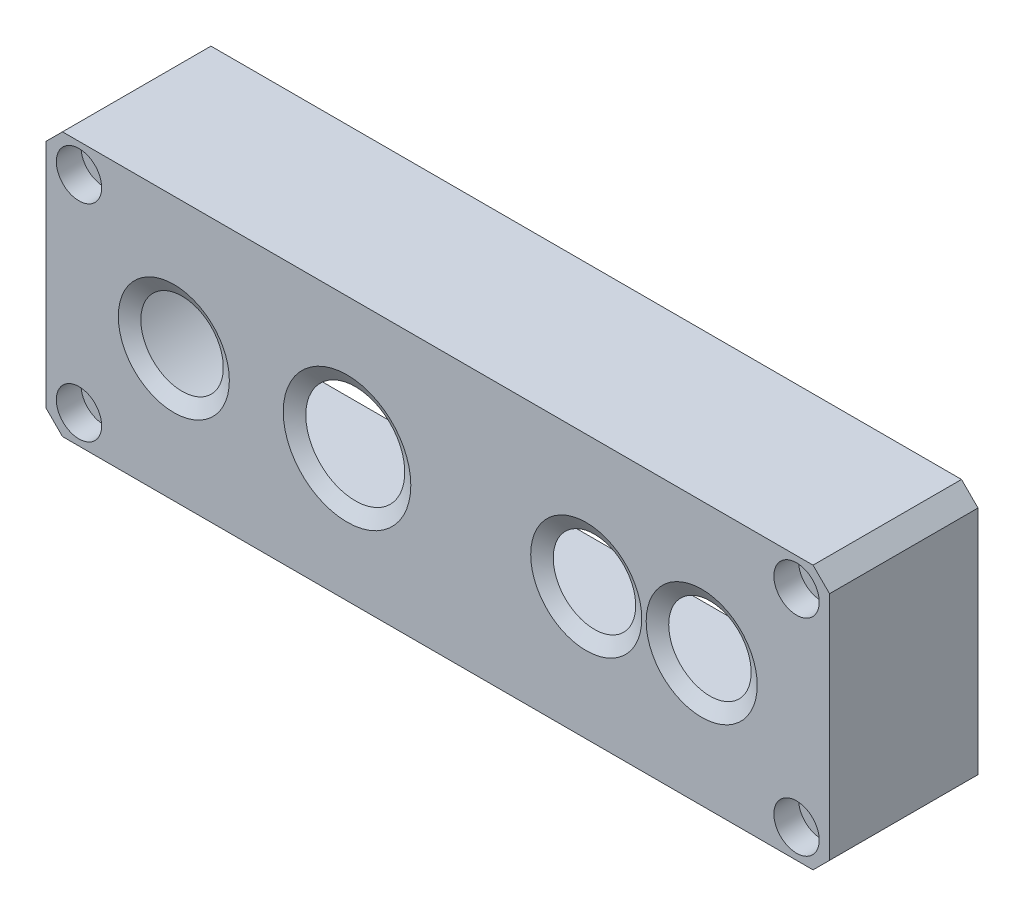
from build123d import *

# Parameters (mm, degrees)
EXTRUDE_1_DEPTH     = 17
SKETCH_2_R          = 6
SKETCH_2_R_2        = 5
EXTRUDE_2_DEPTH     = 1
SKETCH_3_R          = 5
SKETCH_3_R_2        = 6
CUT_EXTRUDE_1_DEPTH = 11
CUT_EXTRUDE_1_TAPER = -60
EXTRUDE_5_DEPTH     = 17
SKETCH_9_R          = 1.3
CUT_EXTRUDE_6_DEPTH = 19.0000001
SKETCH_10_R         = 2.75
CUT_EXTRUDE_7_DEPTH = 3


with BuildPart() as part:
    # 草图1 → 凸台-拉伸1 (new body)
    with BuildSketch(Plane.XY):
        Polygon((-229.462722424, 108.123928313), (-138.462722424, 108.123928313), (-136.462722424, 106.123928313), (-136.462722424, 78.123928313), (-138.462722424, 76.123928313), (-229.462722424, 76.123928313), (-231.462722424, 78.123928313), (-231.462722424, 106.123928313), align=None)
        Polygon((-228.6342953, 106.123928313), (-139.291149549, 106.123928313), (-138.462722424, 105.295501188), (-138.462722424, 78.952355437), (-139.291149549, 78.123928313), (-228.6342953, 78.123928313), (-229.462722424, 78.952355437), (-229.462722424, 105.295501188), align=None, mode=Mode.SUBTRACT)
    extrude(amount=-EXTRUDE_1_DEPTH)

    # 草图2 → 凸台-拉伸2 (add)
    with BuildSketch(Plane.XY):
        Polygon((-136.462722424, 106.123928313), (-138.462722424, 108.123928313), (-229.462722424, 108.123928313), (-231.462722424, 106.123928313), (-231.462722424, 78.123928313), (-229.462722424, 76.123928313), (-138.462722424, 76.123928313), (-136.462722424, 78.123928313), align=None)
        with Locations((-194.962722424, 92.123928313)):
            Circle(SKETCH_2_R, mode=Mode.SUBTRACT)
        with Locations((-165.962722424, 92.123928313)):
            Circle(SKETCH_2_R_2, mode=Mode.SUBTRACT)
        with Locations((-215.962722424, 92.123928313)):
            Circle(SKETCH_2_R_2, mode=Mode.SUBTRACT)
        with Locations((-151.962722424, 92.123928313)):
            Circle(SKETCH_2_R_2, mode=Mode.SUBTRACT)
    extrude(amount=EXTRUDE_2_DEPTH)

    # 草图3 → 切除-拉伸1 (cut)
    with BuildSketch(Plane(origin=(0, 0, 0), x_dir=(-1, 0, 0), z_dir=(0, 0, -1))):
        with Locations((151.962722424, 92.123928313)):
            Circle(SKETCH_3_R)
        with Locations((215.962722424, 92.123928313)):
            Circle(SKETCH_3_R)
        with Locations((194.962722424, 92.123928313)):
            Circle(SKETCH_3_R_2)
        with Locations((165.962722424, 92.123928313)):
            Circle(SKETCH_3_R)
    extrude(amount=-CUT_EXTRUDE_1_DEPTH, taper=CUT_EXTRUDE_1_TAPER, mode=Mode.SUBTRACT)

    # 草图8 → 凸台-拉伸5 (add)
    with BuildSketch(Plane(origin=(0, 0, 0), x_dir=(-1, 0, 0), z_dir=(0, 0, -1))):
        with BuildLine():
            ThreePointArc((229.462722424, 92.123928313), (225.801557189, 83.285093548), (216.962722424, 79.623928313))
            Line((216.962722424, 79.623928313), (150.962722424, 79.623928313))
            ThreePointArc((150.962722424, 79.623928313), (142.123887659, 83.285093548), (138.462722424, 92.123928313))
            Line((138.462722424, 92.123928313), (138.462722424, 78.952355437))
            Line((138.462722424, 78.952355437), (139.291149549, 78.123928313))
            Line((139.291149549, 78.123928313), (228.6342953, 78.123928313))
            Line((228.6342953, 78.123928313), (229.462722424, 78.952355437))
            Line((229.462722424, 78.952355437), (229.462722424, 92.123928313))
        make_face()
        with BuildLine():
            ThreePointArc((216.962722424, 104.623928313), (225.801557189, 100.962763077), (229.462722424, 92.123928313))
            Line((229.462722424, 92.123928313), (229.462722424, 105.295501188))
            Line((229.462722424, 105.295501188), (228.6342953, 106.123928313))
            Line((228.6342953, 106.123928313), (139.291149549, 106.123928313))
            Line((139.291149549, 106.123928313), (138.462722424, 105.295501188))
            Line((138.462722424, 105.295501188), (138.462722424, 92.123928313))
            ThreePointArc((138.462722424, 92.123928313), (142.123887659, 100.962763077), (150.962722424, 104.623928313))
            Line((150.962722424, 104.623928313), (216.962722424, 104.623928313))
        make_face()
    extrude(amount=EXTRUDE_5_DEPTH)

    # 草图9 → 切除-拉伸6 (cut, through all)
    with BuildSketch(Plane(origin=(0, 0, -17), x_dir=(-1, 0, 0), z_dir=(0, 0, -1))):
        with Locations((227.462722424, 79.623928313)):
            Circle(SKETCH_9_R)
        with Locations((227.462722424, 104.623928313)):
            Circle(SKETCH_9_R)
        with Locations((140.462722424, 79.623928313)):
            Circle(SKETCH_9_R)
        with Locations((140.462722424, 104.623928313)):
            Circle(SKETCH_9_R)
    extrude(amount=-CUT_EXTRUDE_6_DEPTH, mode=Mode.SUBTRACT)

    # 草图10 → 切除-拉伸7 (cut)
    with BuildSketch(Plane.XY.offset(1)):
        with Locations((-227.462722424, 104.623928313)):
            Circle(SKETCH_10_R)
        with Locations((-140.462722424, 104.623928313)):
            Circle(SKETCH_10_R)
        with Locations((-227.462722424, 79.623928313)):
            Circle(SKETCH_10_R)
        with Locations((-140.462722424, 79.623928313)):
            Circle(SKETCH_10_R)
    extrude(amount=-CUT_EXTRUDE_7_DEPTH, mode=Mode.SUBTRACT)


solid = part.part
